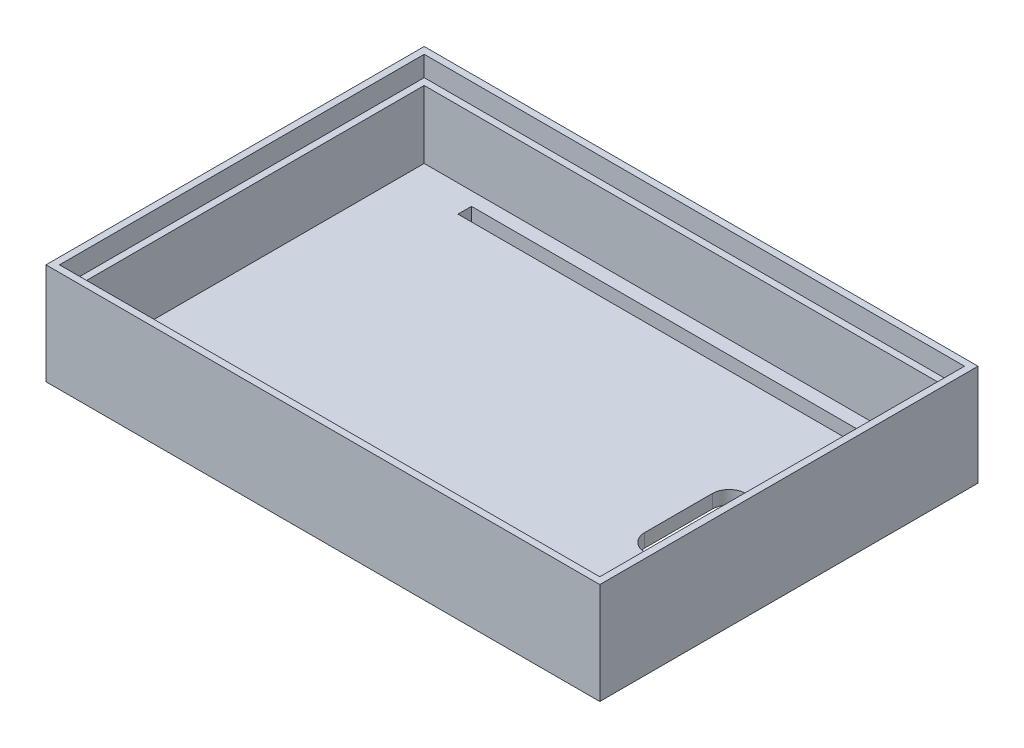
from build123d import *

# Parameters (mm, degrees)
SKETCH1_W           = 82
SKETCH1_H           = 56
BOSS_EXTRUDE1_DEPTH = 15
SKETCH3_W           = 80
SKETCH3_H           = 54
CUT_EXTRUDE1_DEPTH  = 3
CUT_EXTRUDE2_DEPTH  = 10
SKETCH5_W           = 60
SKETCH5_H           = 2
CUT_EXTRUDE3_DEPTH  = 11


with BuildPart() as part:
    # Sketch1 → Boss-Extrude1 (new body)
    with BuildSketch(Plane(origin=(0, 0, 0), x_dir=(1, 0, 0), z_dir=(0, 1, 0))):
        with Locations((41, 28)):
            Rectangle(SKETCH1_W, SKETCH1_H)
    extrude(amount=BOSS_EXTRUDE1_DEPTH)

    # Sketch3 → Cut-Extrude1 (cut)
    with BuildSketch(Plane(origin=(0, 15, 0), x_dir=(1, 0, 0), z_dir=(0, 1, 0))):
        with Locations((41, 28)):
            Rectangle(SKETCH3_W, SKETCH3_H)
    extrude(amount=-CUT_EXTRUDE1_DEPTH, mode=Mode.SUBTRACT)

    # 3DSketch1 → Cut-Extrude2 (cut)
    with BuildSketch(Plane(origin=(80, 12, -2), x_dir=(-0.8320502943378438, 0, -0.554700196225229), z_dir=(0, 1, 0))):
        Polygon((0, 0), (28.844410204, -43.266615306), (93.744333162, 0), (64.899922958, 43.266615306), align=None)
    extrude(amount=-CUT_EXTRUDE2_DEPTH, mode=Mode.SUBTRACT)

    # Sketch5 → Cut-Extrude3 (cut)
    with BuildSketch(Plane.XZ):
        with Locations((41, -5)):
            Rectangle(SKETCH5_W, SKETCH5_H)
        with Locations((41, -51)):
            Rectangle(SKETCH5_W, SKETCH5_H)
        with BuildLine():
            Line((70.653805937, -23), (70.653805937, -25.5))
            ThreePointArc((70.653805937, -25.5), (73.153805937, -28), (70.653805937, -30.5))
            Line((70.653805937, -30.5), (70.653805937, -33))
            ThreePointArc((70.653805937, -33), (68.153805937, -35.5), (65.653805937, -33))
            Line((65.653805937, -33), (65.653805937, -23))
            ThreePointArc((65.653805937, -23), (68.153805937, -20.5), (70.653805937, -23))
        make_face()
    extrude(amount=-CUT_EXTRUDE3_DEPTH, mode=Mode.SUBTRACT)


solid = part.part
